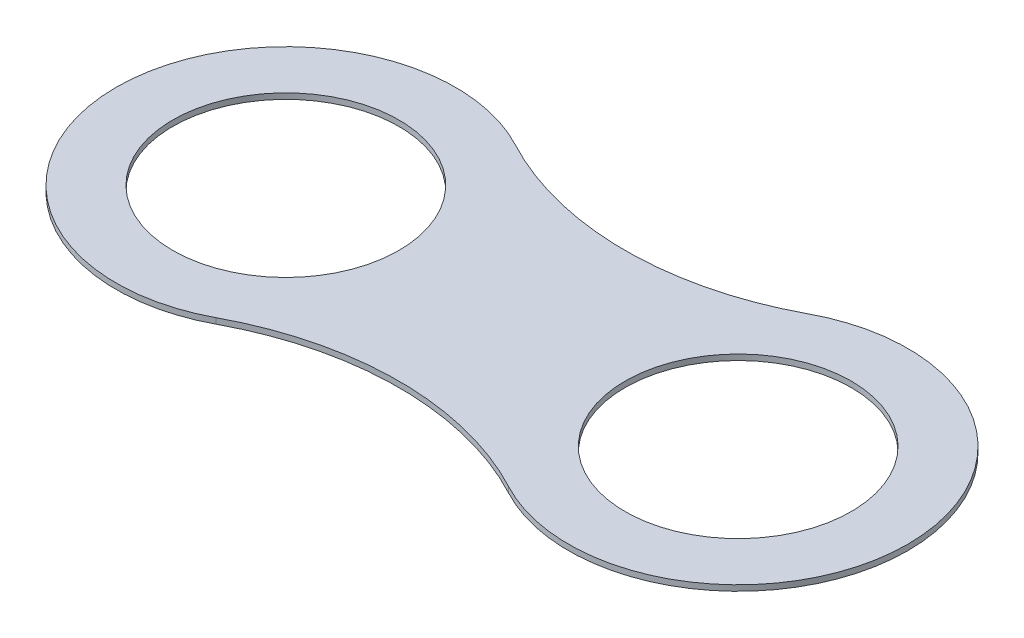
from build123d import *

# Parameters (mm, degrees)
ESQUISSE1_R      = 200
EXTRUSION1_DEPTH = 10


with BuildPart() as part:
    # Esquisse1 → Extrusion1 (new body)
    with BuildSketch(Plane(origin=(0, 0, 0), x_dir=(1, 0, 0), z_dir=(0, 1, 0))):
        with BuildLine():
            ThreePointArc((141.176470588, -264.705882353), (-300, 0), (141.176470588, 264.705882353))
            ThreePointArc((141.176470588, 264.705882353), (400, 200), (658.823529412, 264.705882353))
            ThreePointArc((658.823529412, 264.705882353), (1100, 0), (658.823529412, -264.705882353))
            ThreePointArc((658.823529412, -264.705882353), (400, -200), (141.176470588, -264.705882353))
        make_face()
        Circle(ESQUISSE1_R, mode=Mode.SUBTRACT)
        with Locations((800, 0)):
            Circle(ESQUISSE1_R, mode=Mode.SUBTRACT)
    extrude(amount=EXTRUSION1_DEPTH)


solid = part.part
